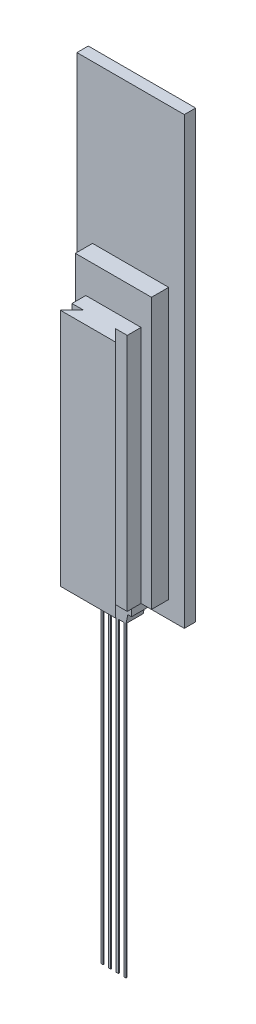
from build123d import *

# Parameters (mm, degrees)
SKETCH1_W           = 3.5
SKETCH1_H           = 14.5
BOSS_EXTRUDE1_DEPTH = 0.37
SKETCH2_W           = 2.48
SKETCH2_H           = 8.81
BOSS_EXTRUDE2_DEPTH = 0.56
SKETCH3_W           = 0.07
SKETCH3_H           = 10
BOSS_EXTRUDE3_DEPTH = 0.03
SKETCH5_W           = 1.8
SKETCH5_H           = 7.79
BOSS_EXTRUDE4_DEPTH = 0.45
BOSS_EXTRUDE5_DEPTH = 7.79


with BuildPart() as part:
    # Sketch1 → Boss-Extrude1 (new body)
    with BuildSketch(Plane.XY):
        Rectangle(SKETCH1_W, SKETCH1_H)
    extrude(amount=BOSS_EXTRUDE1_DEPTH)

    # Sketch2 → Boss-Extrude2 (add)
    with BuildSketch(Plane.XY.offset(0.37)):
        with Locations((0, -2.285)):
            Rectangle(SKETCH2_W, SKETCH2_H)
        Polygon((0.59, -6.69), (-0.59, -6.69), (-0.59, -7.22), (-0.47, -7.22), (0.47, -7.22), (0.59, -7.22), align=None)
        Polygon((0.463655834, -7.25), (-0.463655834, -7.25), (-0.41, -7.503725219), (0.41, -7.503725219), align=None)
        Polygon((0.47, -7.22), (-0.47, -7.22), (-0.463655834, -7.25), (0.463655834, -7.25), align=None)
    extrude(amount=BOSS_EXTRUDE2_DEPTH)

    # Sketch3 → Boss-Extrude3 (add)
    with BuildSketch(Plane.XY.offset(0.93)):
        with Locations((-0.375, -12.503725219)):
            Rectangle(SKETCH3_W, SKETCH3_H)
        with Locations((-0.125, -12.503725219)):
            Rectangle(SKETCH3_W, SKETCH3_H)
        with Locations((0.125, -12.503725219)):
            Rectangle(SKETCH3_W, SKETCH3_H)
        with Locations((0.375, -12.503725219)):
            Rectangle(SKETCH3_W, SKETCH3_H)
    extrude(amount=-BOSS_EXTRUDE3_DEPTH)

    # Sketch5 → Boss-Extrude4 (add)
    with BuildSketch(Plane.XY.offset(0.93)):
        with Locations((0, -2.795)):
            Rectangle(SKETCH5_W, SKETCH5_H)
    extrude(amount=BOSS_EXTRUDE4_DEPTH)

    # Sketch6 → Boss-Extrude5 (add)
    with BuildSketch(Plane.XZ.offset(6.69)):
        Polygon((-0.52, 1.38), (-0.9, 1.76), (0.9, 1.76), (0.52, 1.38), align=None)
    extrude(amount=-BOSS_EXTRUDE5_DEPTH)


solid = part.part
